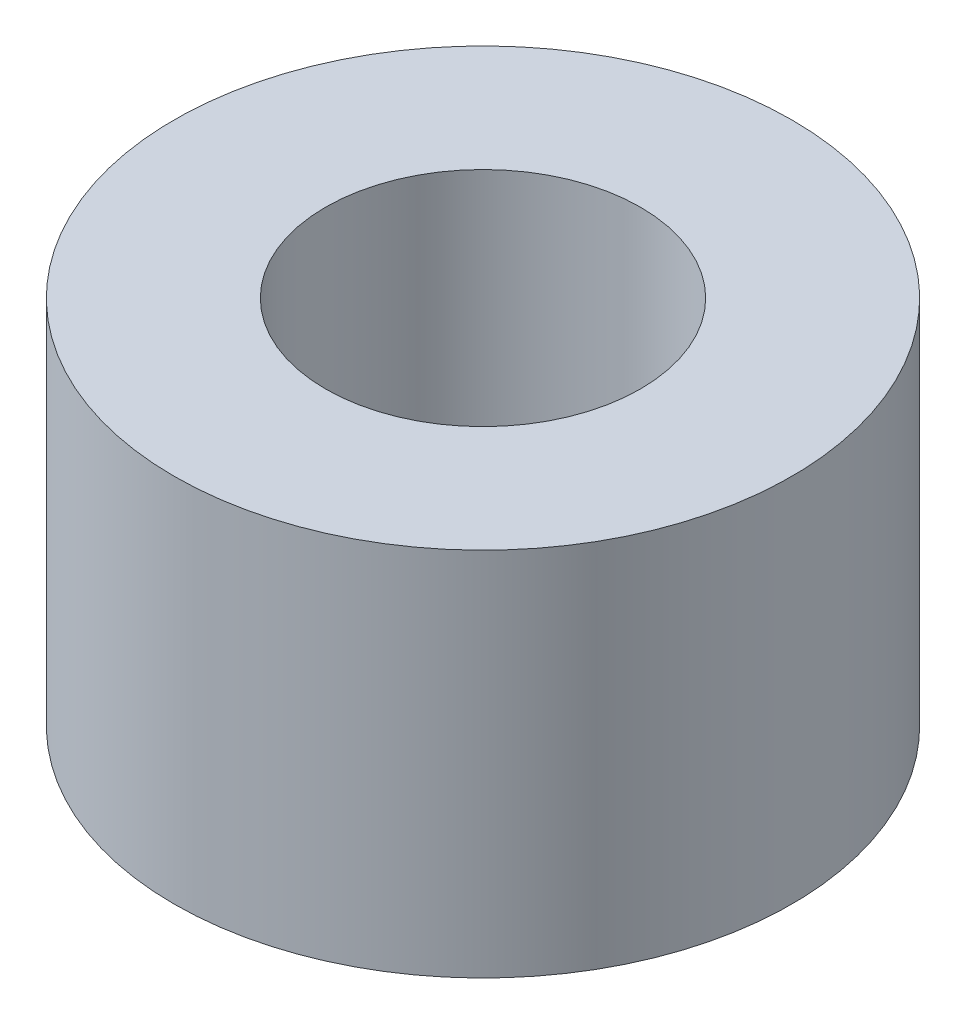
from build123d import *

# Parameters (mm, degrees)
CROQUIS1_R              = 5
CROQUIS1_R_2            = 2.55
SALIENTE_EXTRUIR1_DEPTH = 6


with BuildPart() as part:
    # Croquis1 → Saliente-Extruir1 (new body)
    with BuildSketch(Plane(origin=(0, 0, 0), x_dir=(1, 0, 0), z_dir=(0, 1, 0))):
        Circle(CROQUIS1_R)
        Circle(CROQUIS1_R_2, mode=Mode.SUBTRACT)
    extrude(amount=SALIENTE_EXTRUIR1_DEPTH)


solid = part.part
